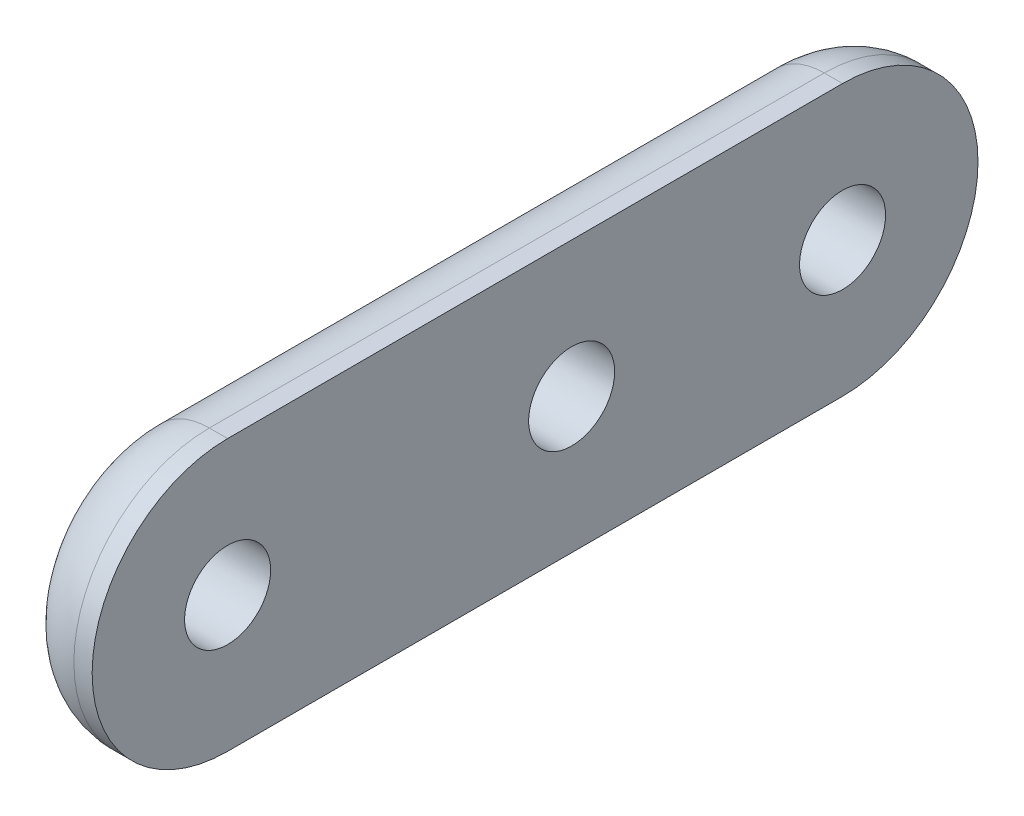
from build123d import *

# Parameters (mm, degrees)
SKETCH2_R           = 3.175
BOSS_EXTRUDE1_DEPTH = 6.35
FILLET1_R           = 5


with BuildPart() as part:
    # Sketch2 → Boss-Extrude1 (new body)
    with BuildSketch(Plane(origin=(0, 0, 0), x_dir=(0, 0, -1), z_dir=(1, 0, 0))):
        with BuildLine():
            Line((-58.176437282, 10), (-12.776437282, 10))
            ThreePointArc((-12.776437282, 10), (-2.776437282, 0), (-12.776437282, -10))
            Line((-12.776437282, -10), (-58.176437282, -10))
            ThreePointArc((-58.176437282, -10), (-68.176437282, 0), (-58.176437282, 10))
        make_face()
        with Locations((-32.776437282, 0)):
            Circle(SKETCH2_R, mode=Mode.SUBTRACT)
        with Locations((-12.776437282, 0)):
            Circle(SKETCH2_R, mode=Mode.SUBTRACT)
        with Locations((-58.176437282, 0)):
            Circle(SKETCH2_R, mode=Mode.SUBTRACT)
    extrude(amount=BOSS_EXTRUDE1_DEPTH)

    # Fillet1
    fillet1_edges = [part.edges().sort_by_distance(p)[0] for p in [
        (0, 10, 35.476437282),
        (0, 0, 2.776437282),
        (0, -10, 35.476437282),
        (0, 0, 68.176437282),
    ]]
    fillet(fillet1_edges, radius=FILLET1_R)


solid = part.part
